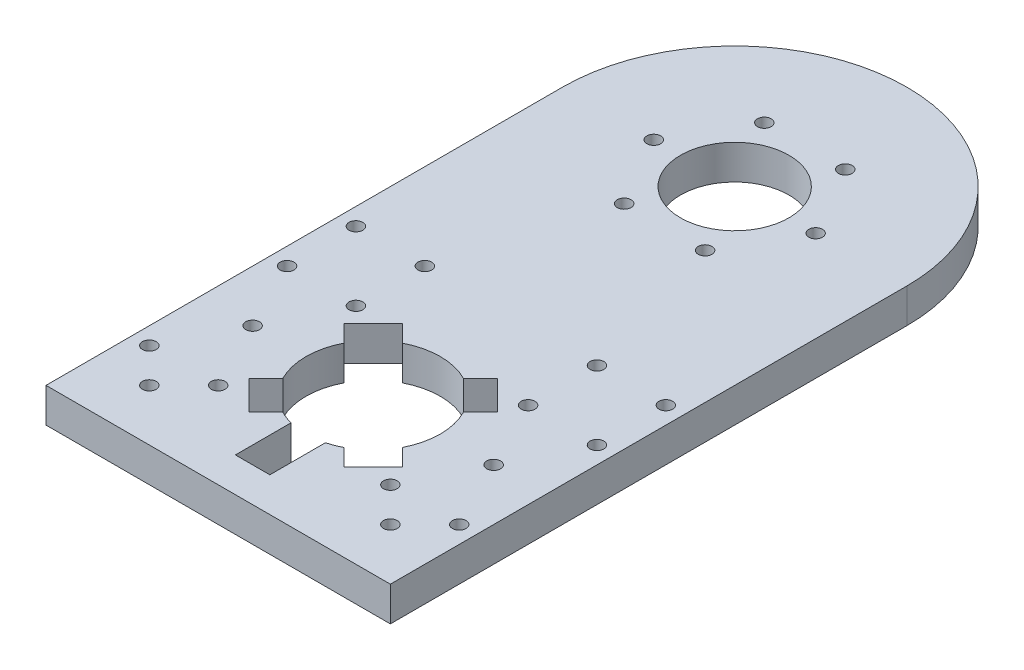
from build123d import *

# Parameters (mm, degrees)
SKETCH1_R           = 15.75
SKETCH1_R_2         = 2
BOSS_EXTRUDE3_DEPTH = 10
SKETCH2_R           = 19.5
CUT_EXTRUDE1_DEPTH  = 10
CUT_EXTRUDE2_DEPTH  = 10
CUT_EXTRUDE3_DEPTH  = 10


with BuildPart() as part:
    # Sketch1 → Boss-Extrude3 (new body)
    with BuildSketch(Plane(origin=(0, 0, 0), x_dir=(1, 0, 0), z_dir=(0, 1, 0))):
        with BuildLine():
            Line((-52.326392464, -141.880675109), (47.673607536, -141.880675109))
            Line((47.673607536, -141.880675109), (47.673607536, 8.119324891))
            ThreePointArc((47.673607536, 8.119324891), (-2.326392464, 58.119324891), (-52.326392464, 8.119324891))
            Line((-52.326392464, 8.119324891), (-52.326392464, -141.880675109))
        make_face()
        with Locations((-2.326392464, 8.119324891)):
            Circle(SKETCH1_R, mode=Mode.SUBTRACT)
        with Locations((21.173607536, 8.119324891)):
            Circle(SKETCH1_R_2, mode=Mode.SUBTRACT)
        with Locations((9.423607536, -12.232272098)):
            Circle(SKETCH1_R_2, mode=Mode.SUBTRACT)
        with Locations((-14.076392464, -12.232272098)):
            Circle(SKETCH1_R_2, mode=Mode.SUBTRACT)
        with Locations((-25.826392464, 8.119324891)):
            Circle(SKETCH1_R_2, mode=Mode.SUBTRACT)
        with Locations((-14.076392464, 28.47092188)):
            Circle(SKETCH1_R_2, mode=Mode.SUBTRACT)
        with Locations((9.423607536, 28.47092188)):
            Circle(SKETCH1_R_2, mode=Mode.SUBTRACT)
        with Locations((-47.326392464, -116.880675109)):
            Circle(SKETCH1_R_2, mode=Mode.SUBTRACT)
        with Locations((42.673607536, -116.880675109)):
            Circle(SKETCH1_R_2, mode=Mode.SUBTRACT)
        with Locations((-37.326392464, -126.880675109)):
            Circle(SKETCH1_R_2, mode=Mode.SUBTRACT)
        with Locations((-37.326392464, -96.880675109)):
            Circle(SKETCH1_R_2, mode=Mode.SUBTRACT)
        with Locations((-47.326392464, -76.880675109)):
            Circle(SKETCH1_R_2, mode=Mode.SUBTRACT)
        with Locations((42.673607536, -76.880675109)):
            Circle(SKETCH1_R_2, mode=Mode.SUBTRACT)
        with Locations((-47.326392464, -56.880675109)):
            Circle(SKETCH1_R_2, mode=Mode.SUBTRACT)
        with Locations((42.673607536, -56.880675109)):
            Circle(SKETCH1_R_2, mode=Mode.SUBTRACT)
        with Locations((-27.326392464, -116.880675109)):
            Circle(SKETCH1_R_2, mode=Mode.SUBTRACT)
        with Locations((22.673607536, -116.880675109)):
            Circle(SKETCH1_R_2, mode=Mode.SUBTRACT)
        with Locations((-27.326392464, -56.880675109)):
            Circle(SKETCH1_R_2, mode=Mode.SUBTRACT)
        with Locations((-27.326392464, -76.880675109)):
            Circle(SKETCH1_R_2, mode=Mode.SUBTRACT)
        with Locations((22.673607536, -56.880675109)):
            Circle(SKETCH1_R_2, mode=Mode.SUBTRACT)
        with Locations((22.673607536, -76.880675109)):
            Circle(SKETCH1_R_2, mode=Mode.SUBTRACT)
        with Locations((32.673607536, -96.880675109)):
            Circle(SKETCH1_R_2, mode=Mode.SUBTRACT)
        with Locations((32.673607536, -126.880675109)):
            Circle(SKETCH1_R_2, mode=Mode.SUBTRACT)
    extrude(amount=BOSS_EXTRUDE3_DEPTH)

    # Sketch2 → Cut-Extrude1 (cut)
    with BuildSketch(Plane(origin=(0, 10, 0), x_dir=(1, 0, 0), z_dir=(0, 1, 0))):
        with Locations((-2.326392464, -96.880675109)):
            Circle(SKETCH2_R)
    extrude(amount=-CUT_EXTRUDE1_DEPTH, mode=Mode.SUBTRACT)

    # Sketch3 → Cut-Extrude2 (cut)
    with BuildSketch(Plane(origin=(0, 10, 0), x_dir=(1, 0, 0), z_dir=(0, 1, 0))):
        with BuildLine():
            Line((-7.326392464, -131.880675109), (-7.326392464, -115.728751934))
            ThreePointArc((-7.326392464, -115.728751934), (-2.326392464, -116.380675109), (2.673607536, -115.728751934))
            Line((2.673607536, -115.728751934), (2.673607536, -131.880675109))
            Line((2.673607536, -131.880675109), (-7.326392464, -131.880675109))
        make_face()
    extrude(amount=-CUT_EXTRUDE2_DEPTH, mode=Mode.SUBTRACT)

    # Sketch4 → Cut-Extrude3 (cut)
    with BuildSketch(Plane(origin=(0, 10, 0), x_dir=(1, 0, 0), z_dir=(0, 1, 0))):
        with BuildLine():
            ThreePointArc((-19.688674915, -88.003674033), (-16.114974697, -83.092092876), (-11.203393541, -79.518392659))
            Line((-11.203393541, -79.518392659), (-16.114974697, -74.606811502))
            Line((-16.114974697, -74.606811502), (-24.600256072, -83.092092876))
            Line((-24.600256072, -83.092092876), (-19.688674915, -88.003674033))
        make_face()
        with BuildLine():
            Line((11.462189769, -74.606811502), (6.550608612, -79.518392659))
            ThreePointArc((6.550608612, -79.518392659), (11.462189769, -83.092092876), (15.035889986, -88.003674033))
            Line((15.035889986, -88.003674033), (19.947471143, -83.092092876))
            Line((19.947471143, -83.092092876), (11.462189769, -74.606811502))
        make_face()
        with BuildLine():
            Line((19.947471143, -110.669257342), (15.035889986, -105.757676186))
            ThreePointArc((15.035889986, -105.757676186), (11.462189769, -110.669257342), (6.550608612, -114.24295756))
            Line((6.550608612, -114.24295756), (11.462189769, -119.154538717))
            Line((11.462189769, -119.154538717), (19.947471143, -110.669257342))
        make_face()
        with BuildLine():
            ThreePointArc((-11.203393541, -114.24295756), (-16.114974697, -110.669257342), (-19.688674915, -105.757676186))
            Line((-19.688674915, -105.757676186), (-24.600256072, -110.669257342))
            Line((-24.600256072, -110.669257342), (-16.114974697, -119.154538717))
            Line((-16.114974697, -119.154538717), (-11.203393541, -114.24295756))
        make_face()
    extrude(amount=-CUT_EXTRUDE3_DEPTH, mode=Mode.SUBTRACT)


solid = part.part
